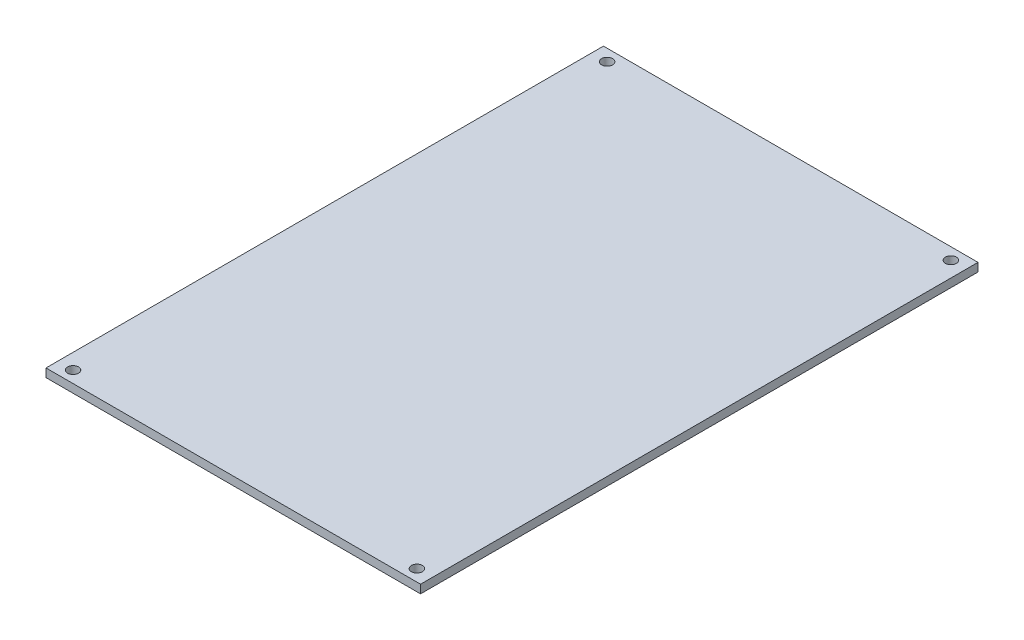
from build123d import *

# Parameters (mm, degrees)
SKETCH_1_W          = 102.4
SKETCH_1_H          = 152.4
EXTRUDE_1_DEPTH     = 2.3
SKETCH_4_R          = 1.5
CUT_EXTRUDE_3_DEPTH = 3.3


with BuildPart() as part:
    # 草圖1 → 填料-伸長1 (new body)
    with BuildSketch(Plane(origin=(0, 0, 0), x_dir=(1, 0, 0), z_dir=(0, 1, 0))):
        Rectangle(SKETCH_1_W, SKETCH_1_H)
    extrude(amount=EXTRUDE_1_DEPTH)

    # 草圖4 → 除料-伸長3 (cut, through all)
    with BuildSketch(Plane(origin=(0, 2.3, 0), x_dir=(1, 0, 0), z_dir=(0, 1, 0))):
        with Locations((-47, 73)):
            Circle(SKETCH_4_R)
        with Locations((47, 73)):
            Circle(SKETCH_4_R)
        with Locations((47, -73)):
            Circle(SKETCH_4_R)
        with Locations((-47, -73)):
            Circle(SKETCH_4_R)
    extrude(amount=-CUT_EXTRUDE_3_DEPTH, mode=Mode.SUBTRACT)


solid = part.part
